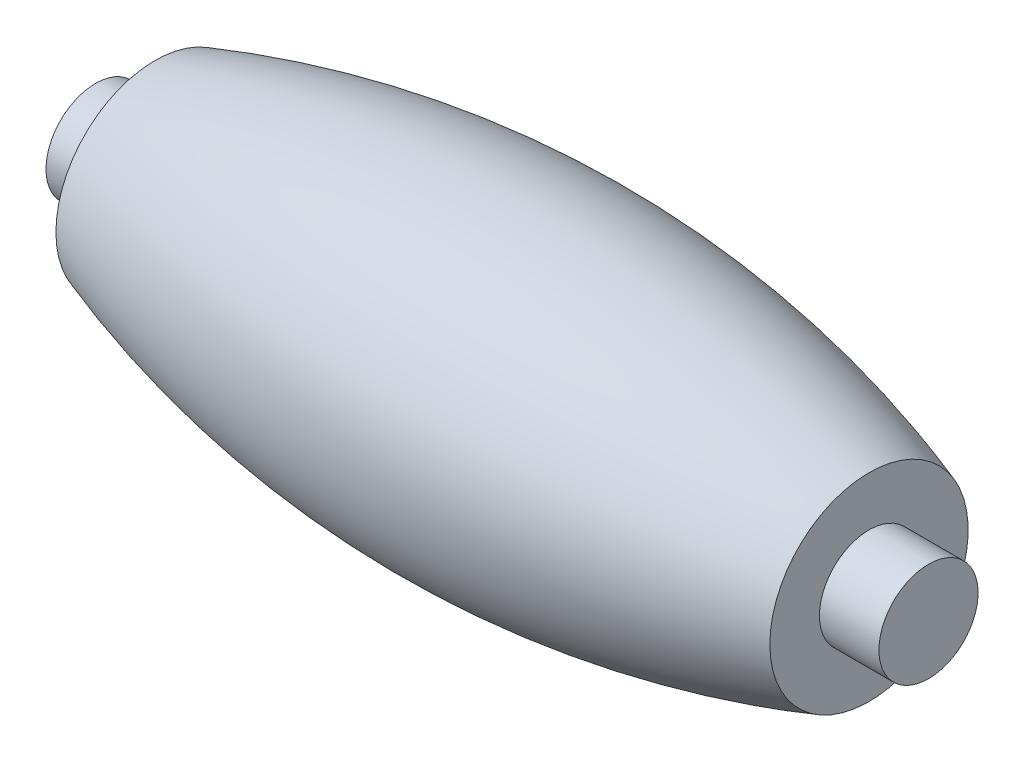
from build123d import *


with BuildPart() as part:
    # Sketch2 → Revolve1 (revolve)
    with BuildSketch(Plane(origin=(0, 0, 0), x_dir=(1, 0, 0), z_dir=(0, 1, 0))):
        with BuildLine():
            Line((0, 0), (0, 2.5))
            Line((0, 2.5), (3, 2.5))
            Line((3, 2.5), (3, 5))
            ThreePointArc((3, 5), (21, 8.00892975), (39, 5))
            Line((39, 5), (39, 2.5))
            Line((39, 2.5), (42, 2.5))
            Line((42, 2.5), (42, 0))
            Line((42, 0), (0, 0))
        make_face()
    revolve(axis=Axis((0, 0, 0), (1, 0, 0)))


solid = part.part
